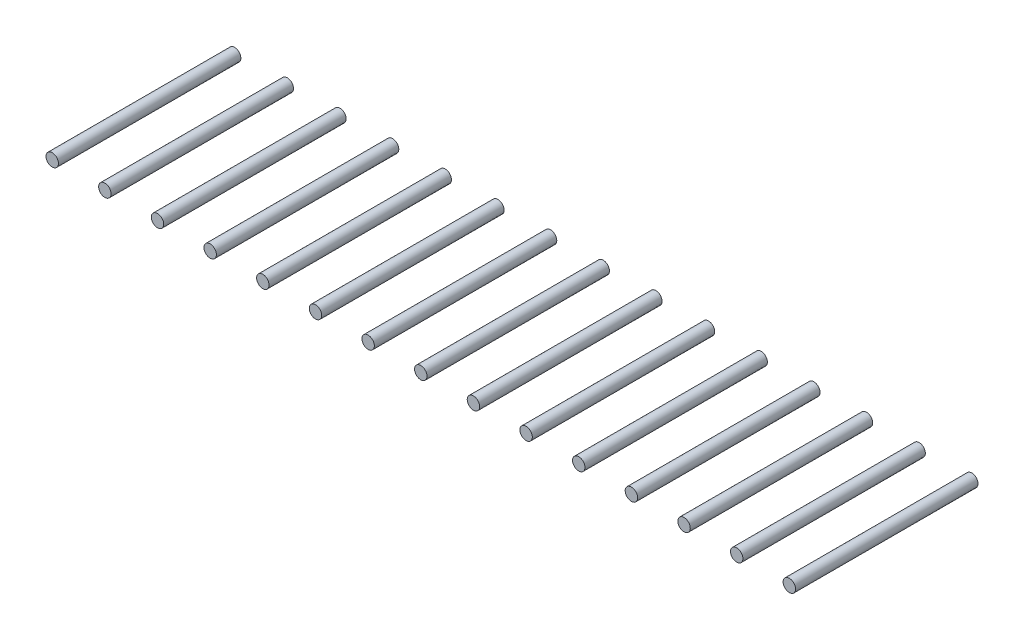
from build123d import *

# Parameters (mm, degrees)
SKETCH_1_R         = 0.3
EXTRUDE_1_DEPTH    = 8.8
EXTRUDE_1_2_DEPTH  = 8.8
EXTRUDE_1_3_DEPTH  = 8.8
EXTRUDE_1_4_DEPTH  = 8.8
EXTRUDE_1_5_DEPTH  = 8.8
EXTRUDE_1_6_DEPTH  = 8.8
EXTRUDE_1_7_DEPTH  = 8.8
EXTRUDE_1_8_DEPTH  = 8.8
EXTRUDE_1_9_DEPTH  = 8.8
EXTRUDE_1_10_DEPTH = 8.8
EXTRUDE_1_11_DEPTH = 8.8
EXTRUDE_1_12_DEPTH = 8.8
EXTRUDE_1_13_DEPTH = 8.8
EXTRUDE_1_14_DEPTH = 8.8
EXTRUDE_1_15_DEPTH = 8.8


with BuildPart() as part:
    # Эскиз1 → Бобышка-Вытянуть1 (new body)
    with BuildSketch(Plane.XY):
        Circle(SKETCH_1_R)
    extrude(amount=EXTRUDE_1_DEPTH)


with BuildPart() as body_2:
    # Эскиз1 → Extrude 1 2 (new body)
    with BuildSketch(Plane.XY):
        with Locations((2.54, 0)):
            Circle(SKETCH_1_R)
    extrude(amount=EXTRUDE_1_2_DEPTH)


with BuildPart() as body_3:
    # Эскиз1 → Extrude 1 3 (new body)
    with BuildSketch(Plane.XY):
        with Locations((5.08, 0)):
            Circle(SKETCH_1_R)
    extrude(amount=EXTRUDE_1_3_DEPTH)


with BuildPart() as body_4:
    # Эскиз1 → Extrude 1 4 (new body)
    with BuildSketch(Plane.XY):
        with Locations((7.62, 0)):
            Circle(SKETCH_1_R)
    extrude(amount=EXTRUDE_1_4_DEPTH)


with BuildPart() as body_5:
    # Эскиз1 → Extrude 1 5 (new body)
    with BuildSketch(Plane.XY):
        with Locations((10.16, 0)):
            Circle(SKETCH_1_R)
    extrude(amount=EXTRUDE_1_5_DEPTH)


with BuildPart() as body_6:
    # Эскиз1 → Extrude 1 6 (new body)
    with BuildSketch(Plane.XY):
        with Locations((12.7, 0)):
            Circle(SKETCH_1_R)
    extrude(amount=EXTRUDE_1_6_DEPTH)


with BuildPart() as body_7:
    # Эскиз1 → Extrude 1 7 (new body)
    with BuildSketch(Plane.XY):
        with Locations((15.24, 0)):
            Circle(SKETCH_1_R)
    extrude(amount=EXTRUDE_1_7_DEPTH)


with BuildPart() as body_8:
    # Эскиз1 → Extrude 1 8 (new body)
    with BuildSketch(Plane.XY):
        with Locations((17.78, 0)):
            Circle(SKETCH_1_R)
    extrude(amount=EXTRUDE_1_8_DEPTH)


with BuildPart() as body_9:
    # Эскиз1 → Extrude 1 9 (new body)
    with BuildSketch(Plane.XY):
        with Locations((20.32, 0)):
            Circle(SKETCH_1_R)
    extrude(amount=EXTRUDE_1_9_DEPTH)


with BuildPart() as body_10:
    # Эскиз1 → Extrude 1 10 (new body)
    with BuildSketch(Plane.XY):
        with Locations((22.86, 0)):
            Circle(SKETCH_1_R)
    extrude(amount=EXTRUDE_1_10_DEPTH)


with BuildPart() as body_11:
    # Эскиз1 → Extrude 1 11 (new body)
    with BuildSketch(Plane.XY):
        with Locations((25.4, 0)):
            Circle(SKETCH_1_R)
    extrude(amount=EXTRUDE_1_11_DEPTH)


with BuildPart() as body_12:
    # Эскиз1 → Extrude 1 12 (new body)
    with BuildSketch(Plane.XY):
        with Locations((27.94, 0)):
            Circle(SKETCH_1_R)
    extrude(amount=EXTRUDE_1_12_DEPTH)


with BuildPart() as body_13:
    # Эскиз1 → Extrude 1 13 (new body)
    with BuildSketch(Plane.XY):
        with Locations((30.48, 0)):
            Circle(SKETCH_1_R)
    extrude(amount=EXTRUDE_1_13_DEPTH)


with BuildPart() as body_14:
    # Эскиз1 → Extrude 1 14 (new body)
    with BuildSketch(Plane.XY):
        with Locations((33.02, 0)):
            Circle(SKETCH_1_R)
    extrude(amount=EXTRUDE_1_14_DEPTH)


with BuildPart() as body_15:
    # Эскиз1 → Extrude 1 15 (new body)
    with BuildSketch(Plane.XY):
        with Locations((35.56, 0)):
            Circle(SKETCH_1_R)
    extrude(amount=EXTRUDE_1_15_DEPTH)


solid = Compound([part.part, body_2.part, body_3.part, body_4.part, body_5.part, body_6.part, body_7.part, body_8.part, body_9.part, body_10.part, body_11.part, body_12.part, body_13.part, body_14.part, body_15.part])
